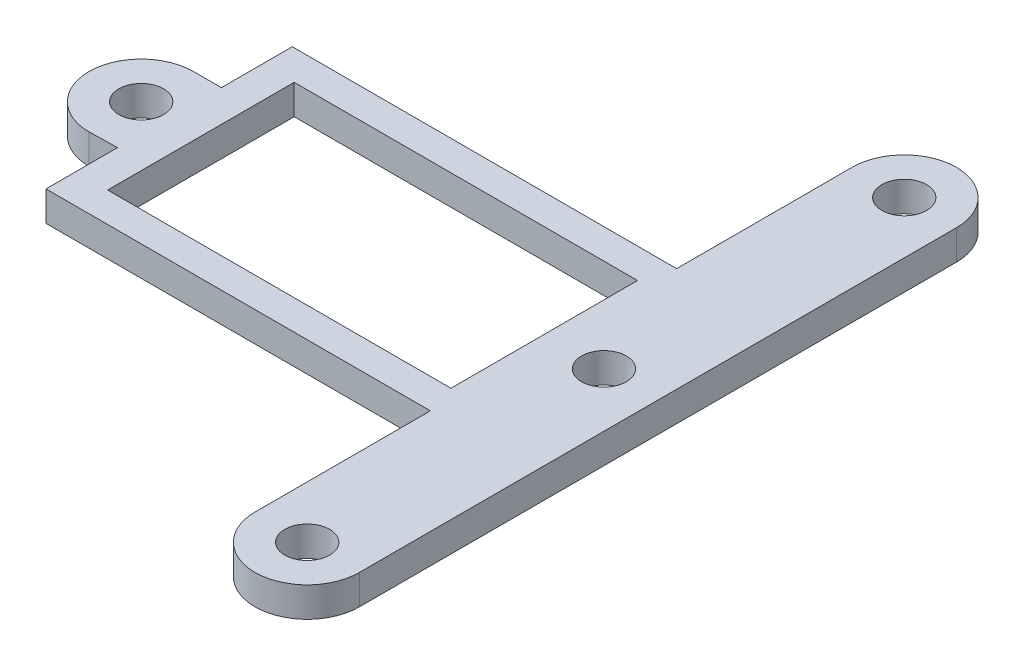
from build123d import *

# Parameters (mm, degrees)
SKETCH1_R           = 1.5
BOSS_EXTRUDE1_DEPTH = 2
SKETCH2_W           = 23
SKETCH2_H           = 12.5
CUT_EXTRUDE1_DEPTH  = 3


with BuildPart() as part:
    # Sketch1 → Boss-Extrude1 (new body)
    with BuildSketch(Plane(origin=(0, 0, 0), x_dir=(1, 0, 0), z_dir=(0, 1, 0))):
        with BuildLine():
            Line((-9.12, -3.457764929), (-9.12, -8.25))
            Line((-9.12, -8.25), (16.63, -8.25))
            Line((16.63, -8.25), (16.63, -20))
            ThreePointArc((16.63, -20), (20.13, -23.5), (23.63, -20))
            Line((23.63, -20), (23.63, 20))
            ThreePointArc((23.63, 20), (20.13, 23.5), (16.63, 20))
            Line((16.63, 20), (16.63, 8.25))
            Line((16.63, 8.25), (-9.12, 8.25))
            Line((-9.12, 8.25), (-9.12, 3.5))
            Line((-9.12, 3.5), (-10.99, 3.5))
            ThreePointArc((-10.99, 3.5), (-14.49, 0), (-10.99, -3.5))
            Line((-10.99, -3.5), (-9.12, -3.457764929))
        make_face()
        with Locations((-10.99, 0)):
            Circle(SKETCH1_R, mode=Mode.SUBTRACT)
        with Locations((20.01, 0)):
            Circle(SKETCH1_R, mode=Mode.SUBTRACT)
        with Locations((20.13, 20)):
            Circle(SKETCH1_R, mode=Mode.SUBTRACT)
        with Locations((20.13, -20)):
            Circle(SKETCH1_R, mode=Mode.SUBTRACT)
    extrude(amount=BOSS_EXTRUDE1_DEPTH)

    # Sketch2 → Cut-Extrude1 (cut, through all)
    with BuildSketch(Plane(origin=(0, 2, 0), x_dir=(1, 0, 0), z_dir=(0, 1, 0))):
        with Locations((4.51, 0)):
            Rectangle(SKETCH2_W, SKETCH2_H)
    extrude(amount=-CUT_EXTRUDE1_DEPTH, mode=Mode.SUBTRACT)


solid = part.part
